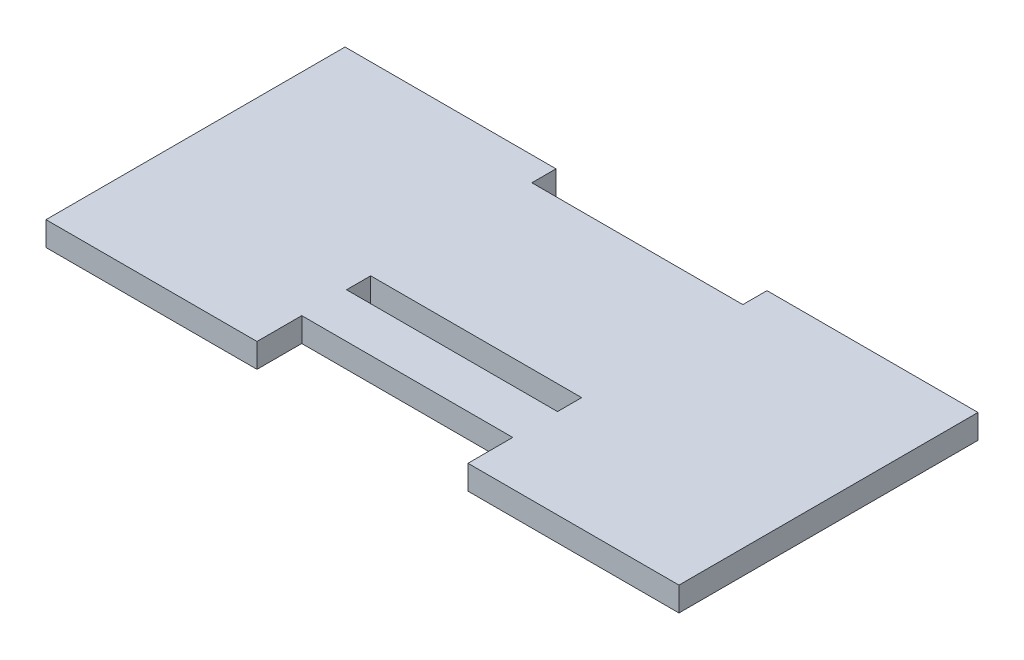
from build123d import *

# Parameters (mm, degrees)
SKETCH1_W           = 23.566666666
SKETCH1_H           = 2.7
BOSS_EXTRUDE1_DEPTH = 2.7


with BuildPart() as part:
    # Sketch1 → Boss-Extrude1 (new body)
    with BuildSketch(Plane(origin=(0, 0, 0), x_dir=(1, 0, 0), z_dir=(0, 1, 0))):
        Polygon((-34.5, -16.7), (-10.933333333, -16.7), (-10.933333333, -11.7), (12.633333333, -11.7), (12.633333333, -16.7), (36.2, -16.7), (36.2, 16.7), (12.633333333, 16.7), (12.633333333, 14), (-10.933333333, 14), (-10.933333333, 16.7), (-34.5, 16.7), align=None)
        with Locations((0.85, -5.35)):
            Rectangle(SKETCH1_W, SKETCH1_H, mode=Mode.SUBTRACT)
    extrude(amount=BOSS_EXTRUDE1_DEPTH)


solid = part.part
